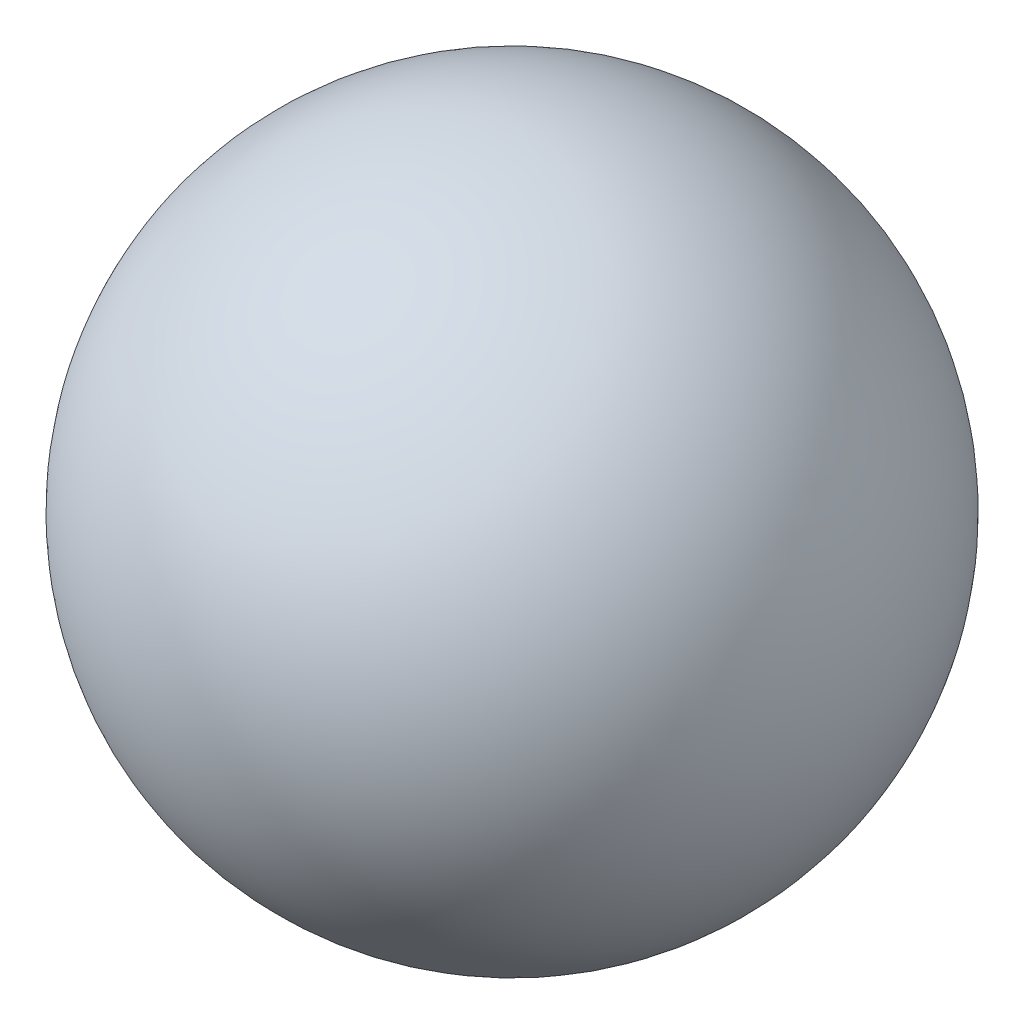
from build123d import *


with BuildPart() as part:
    # Sketch1 → Revolve1 (revolve)
    with BuildSketch(Plane.XY):
        with BuildLine():
            Line((0.28, 0), (-0.28, 0))
            ThreePointArc((-0.28, 0), (0, 0.28), (0.28, 0))
        make_face()
    revolve(axis=Axis((0.28, 0, 0), (-1, 0, 0)))


solid = part.part
